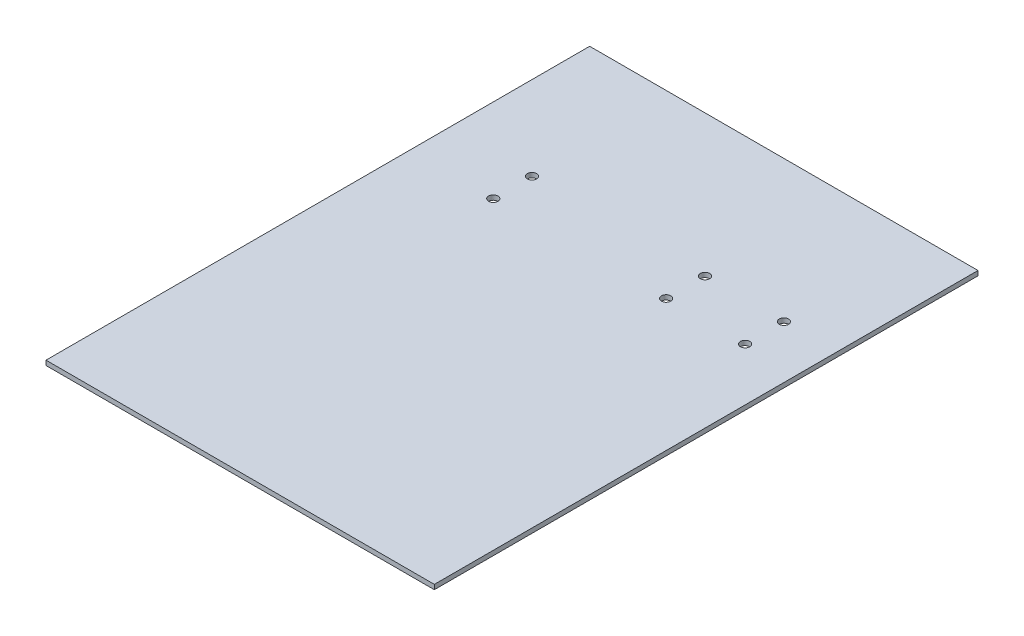
from build123d import *

# Parameters (mm, degrees)
SKETCH2_W                 = 250
SKETCH2_H                 = 350
BOSS_EXTRUDE1_DEPTH       = 3
F_6_0MM_DOWEL_HOLE3_D     = 6
F_6_0MM_DOWEL_HOLE3_DEPTH = 3
F_6_0MM_DOWEL_HOLE4_D     = 6
F_6_0MM_DOWEL_HOLE4_DEPTH = 3


with BuildPart() as part:
    # Sketch2 → Boss-Extrude1 (new body)
    with BuildSketch(Plane(origin=(0, 0, 0), x_dir=(1, 0, 0), z_dir=(0, 1, 0))):
        with Locations((125, 175)):
            Rectangle(SKETCH2_W, SKETCH2_H)
    extrude(amount=BOSS_EXTRUDE1_DEPTH)

    # Ø6.0mm Dowel Hole3
    with Locations(Plane(origin=(0, 0, 0), x_dir=(-1, 0, 0), z_dir=(0, -1, 0))):
        with Locations((-165.242917031, 259), (-216.072996176, 259), (-216.072996176, 234), (-165.242917031, 234)):
            Hole(F_6_0MM_DOWEL_HOLE3_D / 2, depth=F_6_0MM_DOWEL_HOLE3_DEPTH)

    # Ø6.0mm Dowel Hole4
    with Locations(Plane(origin=(0, 3, 0), x_dir=(1, 0, 0), z_dir=(0, 1, 0))):
        with Locations((53.933204471, 259), (53.933204471, 234)):
            Hole(F_6_0MM_DOWEL_HOLE4_D / 2, depth=F_6_0MM_DOWEL_HOLE4_DEPTH)


solid = part.part
